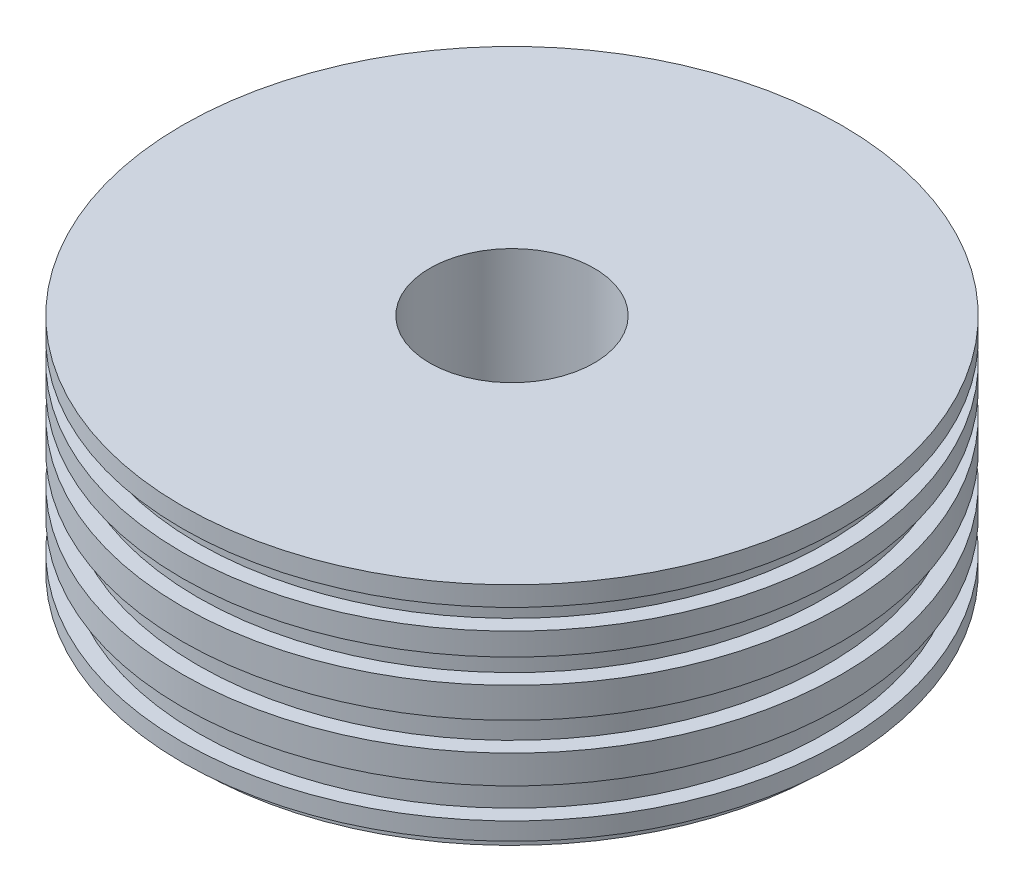
from build123d import *


with BuildPart() as part:
    # Croquis1 → Revolución1 (revolve)
    with BuildSketch(Plane.XY):
        Polygon((40.340283038, -53.066681853), (154.15751018, -53.066681853), (154.15751018, -45.863059882), (161.841373615, -45.863059882), (161.841373615, -37.218713517), (154.15751018, -37.218713517), (154.15751018, -22.33122811), (161.841373615, -22.33122811), (161.841373615, -8.404225633), (154.15751018, -8.404225633), (154.15751018, 5.522776844), (161.841373615, 5.522776844), (161.841373615, 20.410262251), (154.15751018, 20.410262251), (154.15751018, 32.41629887), (161.841373615, 32.41629887), (161.841373615, 43.461852558), (154.15751018, 43.461852558), (154.15751018, 53.546923318), (161.841373615, 53.546923318), (161.841373615, 63.151752613), (40.340283038, 63.151752613), align=None)
    revolve(axis=Axis((0, 53.546923318, 0), (0, -1, 0)))


solid = part.part
